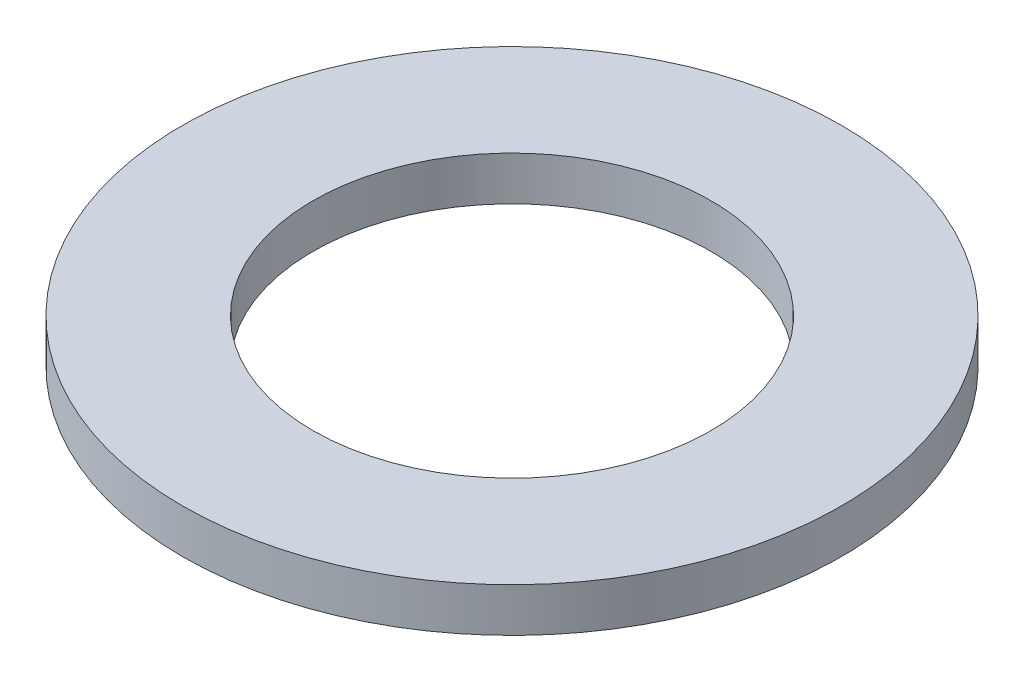
from build123d import *

# Parameters (mm, degrees)
SKETCH1_R           = 9.525
SKETCH1_R_2         = 5.7546875
BOSS_EXTRUDE1_DEPTH = 1.27


with BuildPart() as part:
    # Sketch1 → Boss-Extrude1 (new body)
    with BuildSketch(Plane(origin=(0, 0, 0), x_dir=(1, 0, 0), z_dir=(0, 1, 0))):
        Circle(SKETCH1_R)
        Circle(SKETCH1_R_2, mode=Mode.SUBTRACT)
    extrude(amount=BOSS_EXTRUDE1_DEPTH)


solid = part.part
